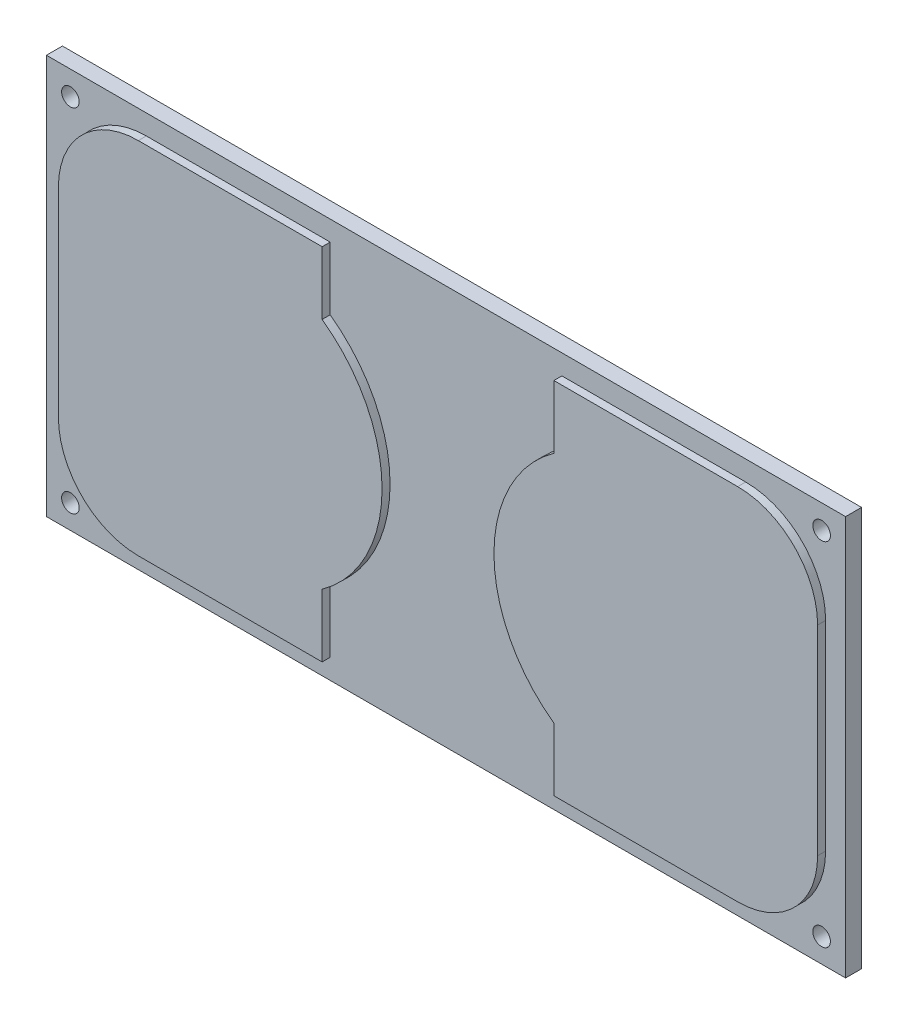
from build123d import *

# Parameters (mm, degrees)
ESQUISSE1_W        = 100
ESQUISSE1_H        = 50
ESQUISSE1_R        = 1.1
BOSS_EXTRU_1_DEPTH = 2
BOSS_EXTRU_2_DEPTH = 1


with BuildPart() as part:
    # Esquisse1 → Boss.-Extru.1 (new body)
    with BuildSketch(Plane.XY):
        with Locations((50, 25)):
            Rectangle(ESQUISSE1_W, ESQUISSE1_H)
        with Locations((3, 47)):
            Circle(ESQUISSE1_R, mode=Mode.SUBTRACT)
        with Locations((97, 47)):
            Circle(ESQUISSE1_R, mode=Mode.SUBTRACT)
        with Locations((3, 3)):
            Circle(ESQUISSE1_R, mode=Mode.SUBTRACT)
        with Locations((97, 3)):
            Circle(ESQUISSE1_R, mode=Mode.SUBTRACT)
    extrude(amount=BOSS_EXTRU_1_DEPTH)

    # Esquisse2 → Boss.-Extru.2 (add)
    with BuildSketch(Plane.XY.offset(2)):
        with BuildLine():
            Line((2.5, 37.5), (2.5, 12.5))
            ThreePointArc((2.5, 12.5), (5.428932188, 5.428932188), (12.5, 2.5))
            Line((12.5, 2.5), (35.5, 2.5))
            Line((35.5, 2.5), (35.5, 10.379808483))
            ThreePointArc((35.5, 10.379808483), (43, 25), (35.5, 39.620191517))
            Line((35.5, 39.620191517), (35.5, 47.5))
            Line((35.5, 47.5), (12.5, 47.5))
            ThreePointArc((12.5, 47.5), (5.428932188, 44.571067812), (2.5, 37.5))
        make_face()
        with BuildLine():
            Line((64.5, 39.620191517), (64.5, 47.5))
            Line((64.5, 47.5), (87.5, 47.5))
            ThreePointArc((87.5, 47.5), (94.571067812, 44.571067812), (97.5, 37.5))
            Line((97.5, 37.5), (97.5, 12.5))
            ThreePointArc((97.5, 12.5), (94.571067812, 5.428932188), (87.5, 2.5))
            Line((87.5, 2.5), (64.5, 2.5))
            Line((64.5, 2.5), (64.5, 10.379808483))
            ThreePointArc((64.5, 10.379808483), (57, 25), (64.5, 39.620191517))
        make_face()
    extrude(amount=BOSS_EXTRU_2_DEPTH)


solid = part.part
